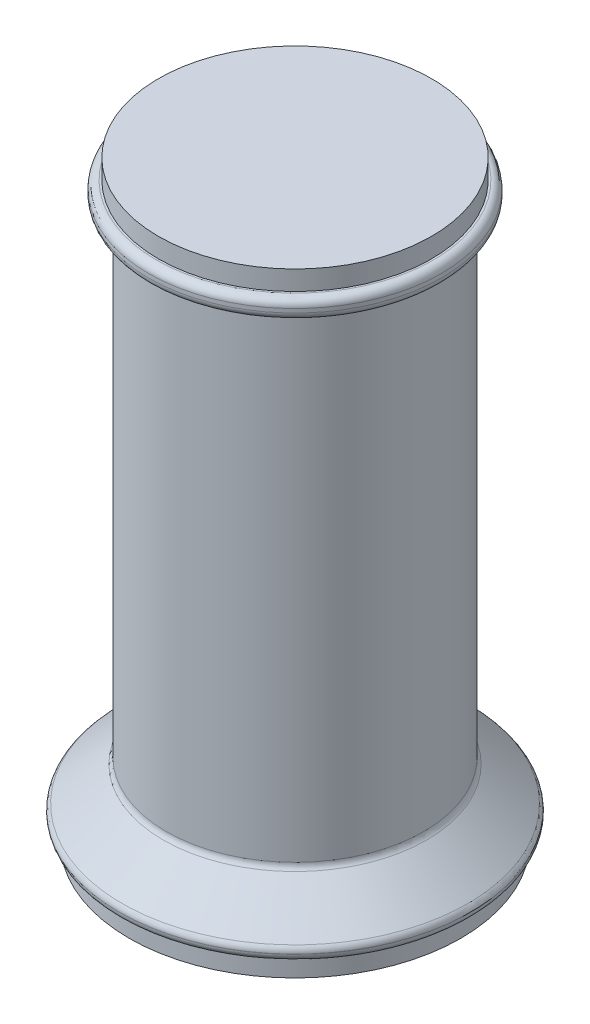
from build123d import *

# Parameters (mm, degrees)
SKETCH1_R           = 42.5
BOSS_EXTRUDE1_DEPTH = 5
SKETCH2_R           = 45
BOSS_EXTRUDE2_DEPTH = 3
SKETCH3_R           = 33
BOSS_EXTRUDE3_START = -18
SKETCH4_R           = 33
BOSS_EXTRUDE3_DEPTH = 142
SKETCH5_R           = 37.5
BOSS_EXTRUDE4_DEPTH = 5
FILLET1_R           = 2
FILLET2_R           = 2
SKETCH7_R           = 35
BOSS_EXTRUDE5_DEPTH = 5


with BuildPart() as part:
    # Sketch1 → Boss-Extrude1 (new body)
    with BuildSketch(Plane(origin=(0, 0, 0), x_dir=(1, 0, 0), z_dir=(0, 1, 0))):
        Circle(SKETCH1_R)
    extrude(amount=BOSS_EXTRUDE1_DEPTH)

    # Sketch2 → Boss-Extrude2 (add)
    with BuildSketch(Plane(origin=(0, 5, 0), x_dir=(1, 0, 0), z_dir=(0, 1, 0))):
        Circle(SKETCH2_R)
    extrude(amount=BOSS_EXTRUDE2_DEPTH)

    # Sketch3 → section 1 of loft1
    with BuildSketch(Plane(origin=(0, 18, 0), x_dir=(1, 0, 0), z_dir=(0, 1, 0)), mode=Mode.PRIVATE) as loft1_s1:
        Circle(SKETCH3_R)
    # loft from a face of the part (loft1)
    loft([part.faces().sort_by_distance((0, 8, 0))[0], loft1_s1.sketch])

    # Sketch4 → Boss-Extrude3 (add)
    with BuildSketch(Plane(origin=(0, 18, 0), x_dir=(1, 0, 0), z_dir=(0, 1, 0)).offset(BOSS_EXTRUDE3_START)):
        Circle(SKETCH4_R)
    extrude(amount=BOSS_EXTRUDE3_DEPTH)

    # Sketch5 → Boss-Extrude4 (add)
    with BuildSketch(Plane(origin=(0, 142, 0), x_dir=(1, 0, 0), z_dir=(0, 1, 0))):
        Circle(SKETCH5_R)
    extrude(amount=BOSS_EXTRUDE4_DEPTH)

    # Fillet1
    fillet1_edges = [part.edges().sort_by_distance(p)[0] for p in [
        (-33, 142, 0),
        (-33, 18, 0),
        (-45, 8, 0),
        (-45, 5, 0),
    ]]
    fillet(fillet1_edges, radius=FILLET1_R)

    # Fillet2
    fillet2_edges = [part.edges().sort_by_distance(p)[0] for p in [
        (-37.5, 142, 0),
        (-37.5, 147, 0),
    ]]
    fillet(fillet2_edges, radius=FILLET2_R)

    # Sketch7 → Boss-Extrude5 (add)
    with BuildSketch(Plane(origin=(0, 147, 0), x_dir=(1, 0, 0), z_dir=(0, 1, 0))):
        Circle(SKETCH7_R)
    extrude(amount=BOSS_EXTRUDE5_DEPTH)


solid = part.part
